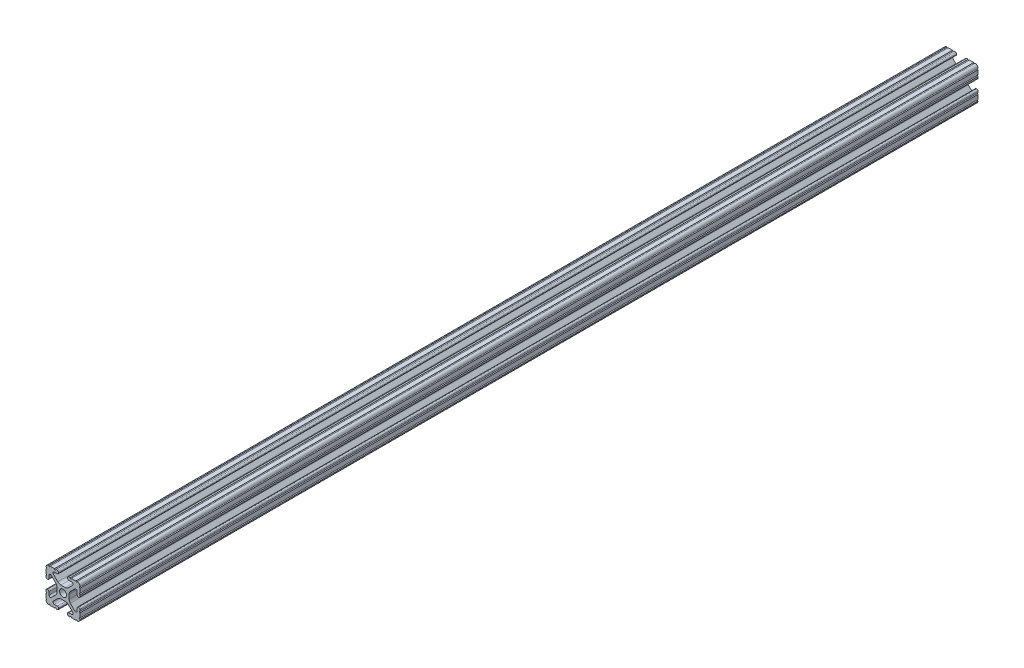
from build123d import *

# Parameters (mm, degrees)
SKETCH1_R           = 2.6035
BOSS_EXTRUDE1_DEPTH = 670


with BuildPart() as part:
    # Sketch1 → Boss-Extrude1 (new body)
    with BuildSketch(Plane.XY):
        with BuildLine():
            Line((-7.179650497, -8.645192506), (-3.952270251, -5.423690499))
            ThreePointArc((-3.952270251, -5.423690499), (-2.922936451, -4.736929036), (-1.709253557, -4.4958))
            Line((-1.709253557, -4.4958), (1.709253557, -4.4958))
            ThreePointArc((1.709253557, -4.4958), (2.922936451, -4.736929036), (3.952270251, -5.423690499))
            Line((3.952270251, -5.423690499), (7.179650497, -8.645192506))
            ThreePointArc((7.179650497, -8.645192506), (7.41473083, -9.822813117), (6.416408329, -10.4902))
            Line((6.416408329, -10.4902), (4.287512407, -10.4902))
            ThreePointArc((4.287512407, -10.4902), (3.54574862, -10.79744862), (3.2385, -11.539212407))
            Line((3.2385, -11.539212407), (3.2385, -11.650987593))
            ThreePointArc((3.2385, -11.650987593), (3.54574862, -12.39275138), (4.287512407, -12.7))
            Line((4.287512407, -12.7), (5.317126718, -12.7))
            ThreePointArc((5.317126718, -12.7), (5.825126718, -12.192), (6.333126718, -12.7))
            Line((6.333126718, -12.7), (9.550443118, -12.7))
            ThreePointArc((9.550443118, -12.7), (10.058366869, -12.192000006), (10.566443095, -12.699847501))
            ThreePointArc((10.566443095, -12.699847501), (12.082537762, -12.08250727), (12.699846982, -10.566399977))
            ThreePointArc((12.699846982, -10.566399977), (12.192000006, -10.058323491), (12.7, -9.5504))
            Line((12.7, -9.5504), (12.7, -6.3330836))
            ThreePointArc((12.7, -6.3330836), (12.192, -5.8250836), (12.7, -5.3170836))
            Line((12.7, -5.3170836), (12.7, -4.287469289))
            ThreePointArc((12.7, -4.287469289), (12.39275138, -3.545705502), (11.650987593, -3.238456882))
            Line((11.650987593, -3.238456882), (11.539212407, -3.238456882))
            ThreePointArc((11.539212407, -3.238456882), (10.79744862, -3.545705502), (10.4902, -4.287469289))
            Line((10.4902, -4.287469289), (10.4902, -6.402089023))
            ThreePointArc((10.4902, -6.402089023), (9.856505071, -7.351067942), (8.737131347, -7.129408934))
            Line((8.737131347, -7.129408934), (5.441005833, -3.840816462))
            ThreePointArc((5.441005833, -3.840816462), (4.750877967, -2.809883091), (4.5085, -1.593185507))
            Line((4.5085, -1.593185507), (4.5085, 1.593185507))
            ThreePointArc((4.5085, 1.593185507), (4.750877967, 2.809883091), (5.441005833, 3.840816462))
            Line((5.441005833, 3.840816462), (8.737131347, 7.129408934))
            ThreePointArc((8.737131347, 7.129408934), (9.856505071, 7.351067942), (10.4902, 6.402089023))
            Line((10.4902, 6.402089023), (10.4902, 4.287469289))
            ThreePointArc((10.4902, 4.287469289), (10.79744862, 3.545705502), (11.539212407, 3.238456882))
            Line((11.539212407, 3.238456882), (11.650987593, 3.238456882))
            ThreePointArc((11.650987593, 3.238456882), (12.39275138, 3.545705502), (12.7, 4.287469289))
            Line((12.7, 4.287469289), (12.7, 5.3170836))
            ThreePointArc((12.7, 5.3170836), (12.192, 5.8250836), (12.7, 6.3330836))
            Line((12.7, 6.3330836), (12.7, 9.5504))
            ThreePointArc((12.7, 9.5504), (12.192000006, 10.058323491), (12.699846982, 10.566399977))
            ThreePointArc((12.699846982, 10.566399977), (12.082537762, 12.08250727), (10.566443095, 12.699847501))
            ThreePointArc((10.566443095, 12.699847501), (10.058366869, 12.192000006), (9.550443118, 12.7))
            Line((9.550443118, 12.7), (6.333126718, 12.7))
            ThreePointArc((6.333126718, 12.7), (5.825126718, 12.192), (5.317126718, 12.7))
            Line((5.317126718, 12.7), (4.287512407, 12.7))
            ThreePointArc((4.287512407, 12.7), (3.54574862, 12.39275138), (3.2385, 11.650987593))
            Line((3.2385, 11.650987593), (3.2385, 11.539212407))
            ThreePointArc((3.2385, 11.539212407), (3.54574862, 10.79744862), (4.287512407, 10.4902))
            Line((4.287512407, 10.4902), (6.476788598, 10.4902))
            ThreePointArc((6.476788598, 10.4902), (7.432222385, 9.85140422), (7.207036008, 8.724370562))
            Line((7.207036008, 8.724370562), (3.898272566, 5.423169045))
            ThreePointArc((3.898272566, 5.423169045), (2.869120213, 4.736787962), (1.655778399, 4.4958))
            Line((1.655778399, 4.4958), (-1.655778399, 4.4958))
            ThreePointArc((-1.655778399, 4.4958), (-2.869120213, 4.736787962), (-3.898272566, 5.423169045))
            Line((-3.898272566, 5.423169045), (-7.207036008, 8.724370562))
            ThreePointArc((-7.207036008, 8.724370562), (-7.432222385, 9.85140422), (-6.476788598, 10.4902))
            Line((-6.476788598, 10.4902), (-4.287512407, 10.4902))
            ThreePointArc((-4.287512407, 10.4902), (-3.54574862, 10.79744862), (-3.2385, 11.539212407))
            Line((-3.2385, 11.539212407), (-3.2385, 11.650987593))
            ThreePointArc((-3.2385, 11.650987593), (-3.54574862, 12.39275138), (-4.287512407, 12.7))
            Line((-4.287512407, 12.7), (-5.317126718, 12.7))
            ThreePointArc((-5.317126718, 12.7), (-5.825126718, 12.192), (-6.333126718, 12.7))
            Line((-6.333126718, 12.7), (-9.550443118, 12.7))
            ThreePointArc((-9.550443118, 12.7), (-10.058366869, 12.192000006), (-10.566443095, 12.699847501))
            ThreePointArc((-10.566443095, 12.699847501), (-12.082537762, 12.08250727), (-12.699846982, 10.566399977))
            ThreePointArc((-12.699846982, 10.566399977), (-12.192000006, 10.058323491), (-12.7, 9.5504))
            Line((-12.7, 9.5504), (-12.7, 6.3330836))
            ThreePointArc((-12.7, 6.3330836), (-12.192, 5.8250836), (-12.7, 5.3170836))
            Line((-12.7, 5.3170836), (-12.7, 4.287469289))
            ThreePointArc((-12.7, 4.287469289), (-12.39275138, 3.545705502), (-11.650987593, 3.238456882))
            Line((-11.650987593, 3.238456882), (-11.539212407, 3.238456882))
            ThreePointArc((-11.539212407, 3.238456882), (-10.79744862, 3.545705502), (-10.4902, 4.287469289))
            Line((-10.4902, 4.287469289), (-10.4902, 6.402089023))
            ThreePointArc((-10.4902, 6.402089023), (-9.856505071, 7.351067942), (-8.737131347, 7.129408934))
            Line((-8.737131347, 7.129408934), (-5.441005833, 3.840816462))
            ThreePointArc((-5.441005833, 3.840816462), (-4.750877967, 2.809883091), (-4.5085, 1.593185507))
            Line((-4.5085, 1.593185507), (-4.5085, -1.593185507))
            ThreePointArc((-4.5085, -1.593185507), (-4.750877967, -2.809883091), (-5.441005833, -3.840816462))
            Line((-5.441005833, -3.840816462), (-8.737131347, -7.129408934))
            ThreePointArc((-8.737131347, -7.129408934), (-9.856505071, -7.351067942), (-10.4902, -6.402089023))
            Line((-10.4902, -6.402089023), (-10.4902, -4.287469289))
            ThreePointArc((-10.4902, -4.287469289), (-10.79744862, -3.545705502), (-11.539212407, -3.238456882))
            Line((-11.539212407, -3.238456882), (-11.650987593, -3.238456882))
            ThreePointArc((-11.650987593, -3.238456882), (-12.39275138, -3.545705502), (-12.7, -4.287469289))
            Line((-12.7, -4.287469289), (-12.7, -5.3170836))
            ThreePointArc((-12.7, -5.3170836), (-12.192, -5.8250836), (-12.7, -6.3330836))
            Line((-12.7, -6.3330836), (-12.7, -9.5504))
            ThreePointArc((-12.7, -9.5504), (-12.192000006, -10.058323491), (-12.699846982, -10.566399977))
            ThreePointArc((-12.699846982, -10.566399977), (-12.082537762, -12.08250727), (-10.566443095, -12.699847501))
            ThreePointArc((-10.566443095, -12.699847501), (-10.058366869, -12.192000006), (-9.550443118, -12.7))
            Line((-9.550443118, -12.7), (-6.333126718, -12.7))
            ThreePointArc((-6.333126718, -12.7), (-5.825126718, -12.192), (-5.317126718, -12.7))
            Line((-5.317126718, -12.7), (-4.287512407, -12.7))
            ThreePointArc((-4.287512407, -12.7), (-3.54574862, -12.39275138), (-3.2385, -11.650987593))
            Line((-3.2385, -11.650987593), (-3.2385, -11.539212407))
            ThreePointArc((-3.2385, -11.539212407), (-3.54574862, -10.79744862), (-4.287512407, -10.4902))
            Line((-4.287512407, -10.4902), (-6.416408329, -10.4902))
            ThreePointArc((-6.416408329, -10.4902), (-7.41473083, -9.822813117), (-7.179650497, -8.645192506))
        make_face()
        Circle(SKETCH1_R, mode=Mode.SUBTRACT)
    extrude(amount=BOSS_EXTRUDE1_DEPTH)


solid = part.part
